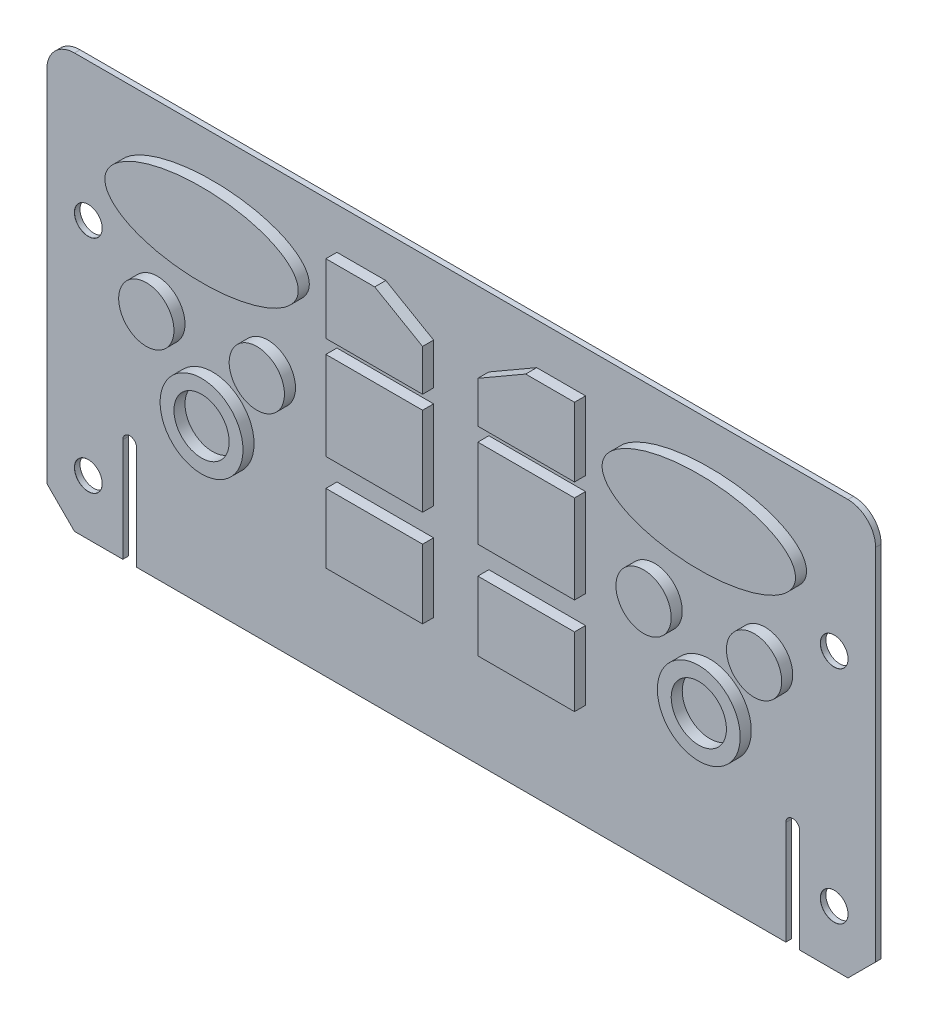
from build123d import *

# Parameters (mm, degrees)
SKETCH1_W                        = 300
SKETCH1_H                        = 150
PCB_BASE_DEPTH                   = 1
SKETCH2_R                        = 10
SKETCH2_R_2                      = 15
SKETCH2_RX                       = 35
SKETCH2_RY                       = 15
SKETCH2_W                        = 35
SKETCH2_H                        = 25
SKETCH2_H_2                      = 32
PCB_CHIPS_DEPTH                  = 4
SLOT_CUT_DEPTH                   = 10
F_10_0MM_DOWEL_HOLE1_D           = 10
F_10_0MM_DOWEL_HOLE1_DEPTH       = 10
F_10_0MM_DOWEL_HOLE1_CSINK_D     = 10.05
F_10_0MM_DOWEL_HOLE1_CSINK_ANGLE = 90
F_10_0MM_DOWEL_HOLE1_TIP         = 3.004303095
FILLET1_R                        = 10
CHAMFER1_SIZE                    = 10


with BuildPart() as part:
    # Sketch1 → PCB Base (new body, symmetric)
    with BuildSketch(Plane.XY):
        with Locations((-150, 75)):
            Rectangle(SKETCH1_W, SKETCH1_H)
    extrude(amount=PCB_BASE_DEPTH, both=True)

    # Sketch2 → PCB Chips (add)
    with BuildSketch(Plane.XY.offset(1)):
        with Locations((-260, 85)):
            Circle(SKETCH2_R)
        with Locations((-220, 85)):
            Circle(SKETCH2_R)
        with Locations((-240, 60)):
            Circle(SKETCH2_R_2)
        with Locations((-240, 60)):
            Circle(SKETCH2_R, mode=Mode.SUBTRACT)
        with Locations((-60, 60)):
            Circle(SKETCH2_R_2)
        with Locations((-60, 60)):
            Circle(SKETCH2_R, mode=Mode.SUBTRACT)
        with Locations((-80, 85)):
            Circle(SKETCH2_R)
        with Locations((-40, 85)):
            Circle(SKETCH2_R)
        with Locations((-240, 120)):
            Ellipse(SKETCH2_RX, SKETCH2_RY)
        with Locations((-60, 120)):
            Ellipse(SKETCH2_RX, SKETCH2_RY)
        with Locations((-177.5, 50.5)):
            Rectangle(SKETCH2_W, SKETCH2_H)
        with Locations((-177.5, 89)):
            Rectangle(SKETCH2_W, SKETCH2_H_2)
        Polygon((-195, 110), (-160, 110), (-160, 125), (-177.320508076, 135), (-195, 135), align=None)
        Polygon((-140, 125), (-122.679491924, 135), (-105, 135), (-105, 110), (-140, 110), align=None)
        with Locations((-122.5, 89)):
            Rectangle(SKETCH2_W, SKETCH2_H_2)
        with Locations((-122.5, 50.5)):
            Rectangle(SKETCH2_W, SKETCH2_H)
    pcb_chips = extrude(amount=PCB_CHIPS_DEPTH)

    # Mirror Chips: PCB Chips across plane
    add(pcb_chips.mirror(Plane.XY))

    # Sketch3 → Slot Cut (cut)
    with BuildSketch(Plane.XY.offset(1)):
        with BuildLine():
            Line((-272.5, 37.5), (-272.5, 0))
            Line((-272.5, 0), (-267.5, 0))
            Line((-267.5, 0), (-267.5, 37.5))
            ThreePointArc((-267.5, 37.5), (-270, 40), (-272.5, 37.5))
        make_face()
        with BuildLine():
            Line((-32.5, 0), (-32.5, 37.5))
            ThreePointArc((-32.5, 37.5), (-30, 40), (-27.5, 37.5))
            Line((-27.5, 37.5), (-27.5, 0))
            ThreePointArc((-27.5, 0), (-30, -2.5), (-32.5, 0))
        make_face()
    extrude(amount=-SLOT_CUT_DEPTH, mode=Mode.SUBTRACT)

    # Ø10.0mm Dowel Hole1
    with Locations(Plane.XY.offset(1)):
        with Locations((-285, 100), (-285, 20), (-15, 20), (-15, 100)):
            CounterSinkHole(F_10_0MM_DOWEL_HOLE1_D / 2, F_10_0MM_DOWEL_HOLE1_CSINK_D / 2, depth=F_10_0MM_DOWEL_HOLE1_DEPTH, counter_sink_angle=F_10_0MM_DOWEL_HOLE1_CSINK_ANGLE)
            with Locations((0, 0, -(F_10_0MM_DOWEL_HOLE1_DEPTH + F_10_0MM_DOWEL_HOLE1_TIP / 2))):  # 118° drill point
                Cone(0, F_10_0MM_DOWEL_HOLE1_D / 2, F_10_0MM_DOWEL_HOLE1_TIP, mode=Mode.SUBTRACT)

    # Fillet1
    fillet1_edges = [part.edges().sort_by_distance(p)[0] for p in [
        (0, 150, 0),
        (-300, 150, 0),
    ]]
    fillet(fillet1_edges, radius=FILLET1_R)

    # Chamfer1
    chamfer1_edges = [part.edges().sort_by_distance(p)[0] for p in [
        (0, 0, 0),
        (-300, 0, 0),
    ]]
    chamfer(chamfer1_edges, length=CHAMFER1_SIZE)


solid = part.part
